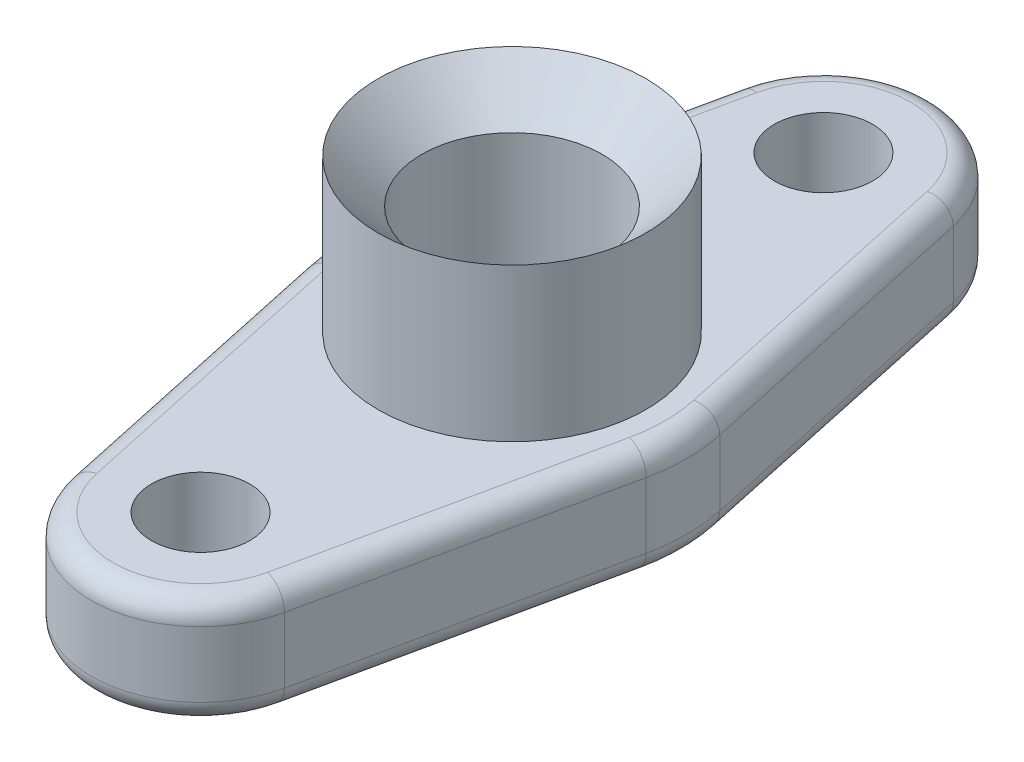
from build123d import *
from OCP.BRepFilletAPI import BRepFilletAPI_MakeFillet

# Parameters (mm, degrees)
SKETCH1_R           = 13.096875
SKETCH1_R_2         = 7.14375
BOSS_EXTRUDE1_DEPTH = 15.875
FILLET3_R1          = 3.175
FILLET3_R2          = 2.54


with BuildPart() as part:
    # Sketch1 → Boss-Extrude1 (new body)
    with BuildSketch(Plane(origin=(0, 0, 0), x_dir=(1, 0, 0), z_dir=(0, 1, 0))):
        with BuildLine():
            Line((24.830740041, 5.347368421), (15.519212525, 48.585855263))
            ThreePointArc((15.519212525, 48.585855263), (0, 61.11875), (-15.519212525, 48.585855263))
            Line((-15.519212525, 48.585855263), (-24.830740041, 5.347368421))
            ThreePointArc((-24.830740041, 5.347368421), (-25.4, 0), (-24.830740041, -5.347368421))
            Line((-24.830740041, -5.347368421), (-15.519212525, -48.585855263))
            ThreePointArc((-15.519212525, -48.585855263), (0, -61.11875), (15.519212525, -48.585855263))
            Line((15.519212525, -48.585855263), (24.830740041, -5.347368421))
            ThreePointArc((24.830740041, -5.347368421), (25.4, 0), (24.830740041, 5.347368421))
        make_face()
        Circle(SKETCH1_R, mode=Mode.SUBTRACT)
        with Locations((0, 45.24375)):
            Circle(SKETCH1_R_2, mode=Mode.SUBTRACT)
        with Locations((0, -45.24375)):
            Circle(SKETCH1_R_2, mode=Mode.SUBTRACT)
    extrude(amount=BOSS_EXTRUDE1_DEPTH)

    # Sketch2 → Revolve1 (revolve)
    with BuildSketch(Plane.XY):
        Polygon((13.096875, 31.75), (19.446875, 38.1), (19.446875, -3.175), (13.096875, -3.175), align=None)
    revolve(axis=Axis((0, -3.175, 0), (0, 1, 0)))

    # Fillet3: one fillet with a radius per group of edges: ONE call of the kernel's fillet builder (fillet() takes one radius for all edges)
    fillet3_edges_1 = [part.edges().sort_by_distance(p)[0] for p in [
        (20.174976283, 0, 26.966611842),
        (25.4, 15.875, 0),
    ]]
    fillet3_edges_2 = [part.edges().sort_by_distance(p)[0] for p in [
        (-19.446875, 0, 0),
    ]]
    fillet3 = BRepFilletAPI_MakeFillet(part.part.solid().wrapped)
    for e in fillet3_edges_1:
        fillet3.Add(FILLET3_R1, e.wrapped)
    for e in fillet3_edges_2:
        fillet3.Add(FILLET3_R2, e.wrapped)
    add(Compound.cast(fillet3.Shape()), mode=Mode.REPLACE)


solid = part.part
